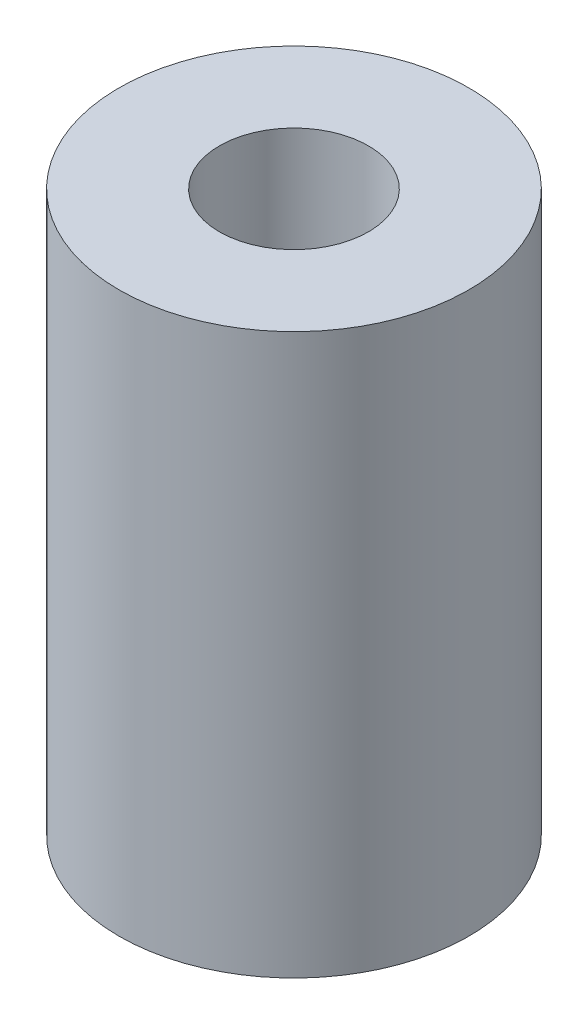
from build123d import *

# Parameters (mm, degrees)
SKETCH1_R             = 3.175
BOSS_EXTRUDE1_DEPTH   = 10.16
F_2_CLEARANCE_HOLE1_D = 2.7051


with BuildPart() as part:
    # Sketch1 → Boss-Extrude1 (new body)
    with BuildSketch(Plane(origin=(0, 0, 0), x_dir=(1, 0, 0), z_dir=(0, 1, 0))):
        Circle(SKETCH1_R)
    extrude(amount=BOSS_EXTRUDE1_DEPTH)

    # #2 Clearance Hole1 (through all)
    with Locations(Plane(origin=(0, 10.16, 0), x_dir=(1, 0, 0), z_dir=(0, 1, 0))):
        with Locations((0, 0)):
            Hole(F_2_CLEARANCE_HOLE1_D / 2)


solid = part.part
